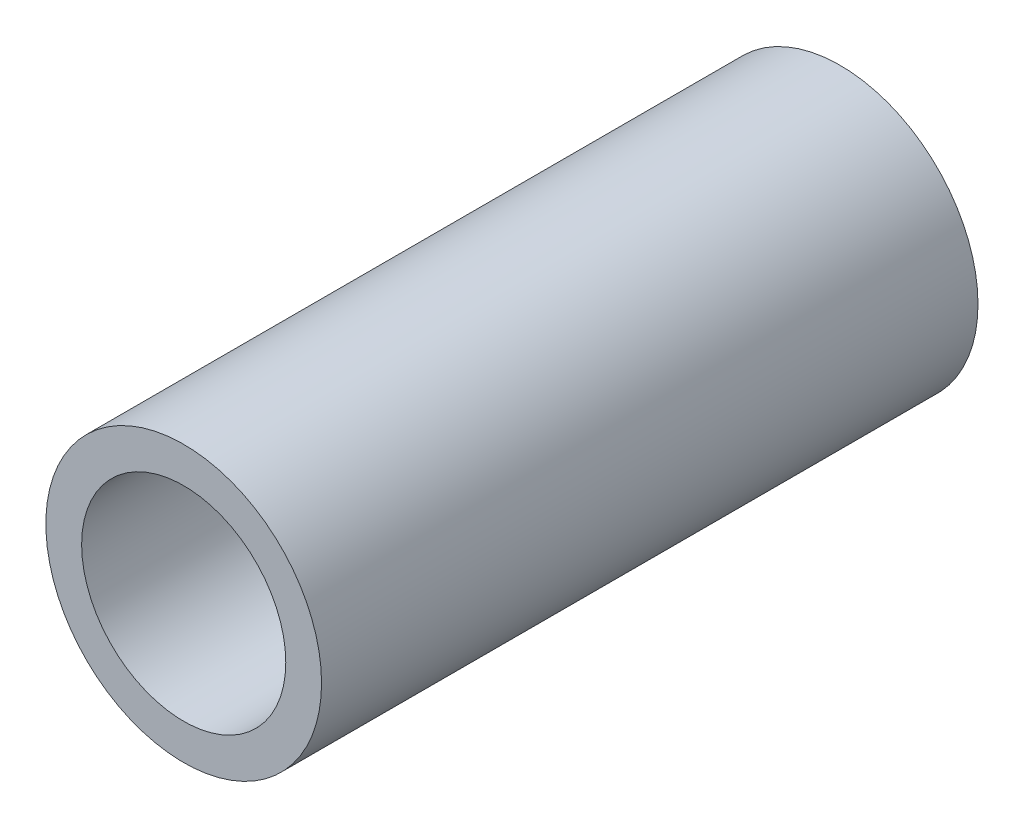
from build123d import *

# Parameters (mm, degrees)
SKETCH1_R           = 10.668
SKETCH1_R_2         = 7.8994
BOSS_EXTRUDE1_DEPTH = 50.8


with BuildPart() as part:
    # Sketch1 → Boss-Extrude1 (new body)
    with BuildSketch(Plane.XY):
        Circle(SKETCH1_R)
        Circle(SKETCH1_R_2, mode=Mode.SUBTRACT)
    extrude(amount=BOSS_EXTRUDE1_DEPTH)


solid = part.part
